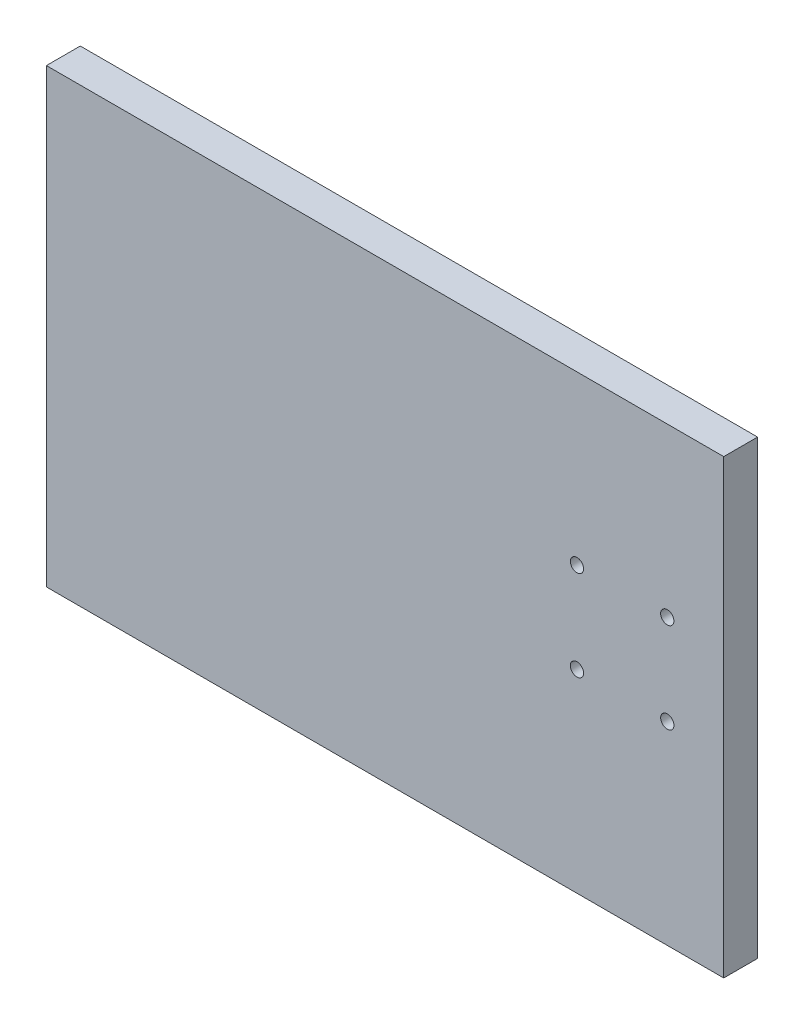
from build123d import *

# Parameters (mm, degrees)
ESQUISSE1_W             = 120
ESQUISSE1_H             = 80
BOSS_EXTRU_1_DEPTH      = 6
ESQUISSE2_R             = 1.175
ENL_V_MAT_EXTRU_1_DEPTH = 6


with BuildPart() as part:
    # Esquisse1 → Boss.-Extru.1 (new body)
    with BuildSketch(Plane.XY):
        with Locations((-4.015872064, 2.185897225)):
            Rectangle(ESQUISSE1_W, ESQUISSE1_H)
    extrude(amount=BOSS_EXTRU_1_DEPTH)

    # Esquisse2 → Enlèv. mat.-Extru.1 (cut)
    with BuildSketch(Plane.XY.offset(6)):
        with Locations((45.984127936, 12.535897225)):
            Circle(ESQUISSE2_R)
        with Locations((29.984127936, 12.535897225)):
            Circle(ESQUISSE2_R)
        with Locations((29.984127936, -3.464102775)):
            Circle(ESQUISSE2_R)
        with Locations((45.984127936, -3.464102775)):
            Circle(ESQUISSE2_R)
    extrude(amount=-ENL_V_MAT_EXTRU_1_DEPTH, mode=Mode.SUBTRACT)


solid = part.part
